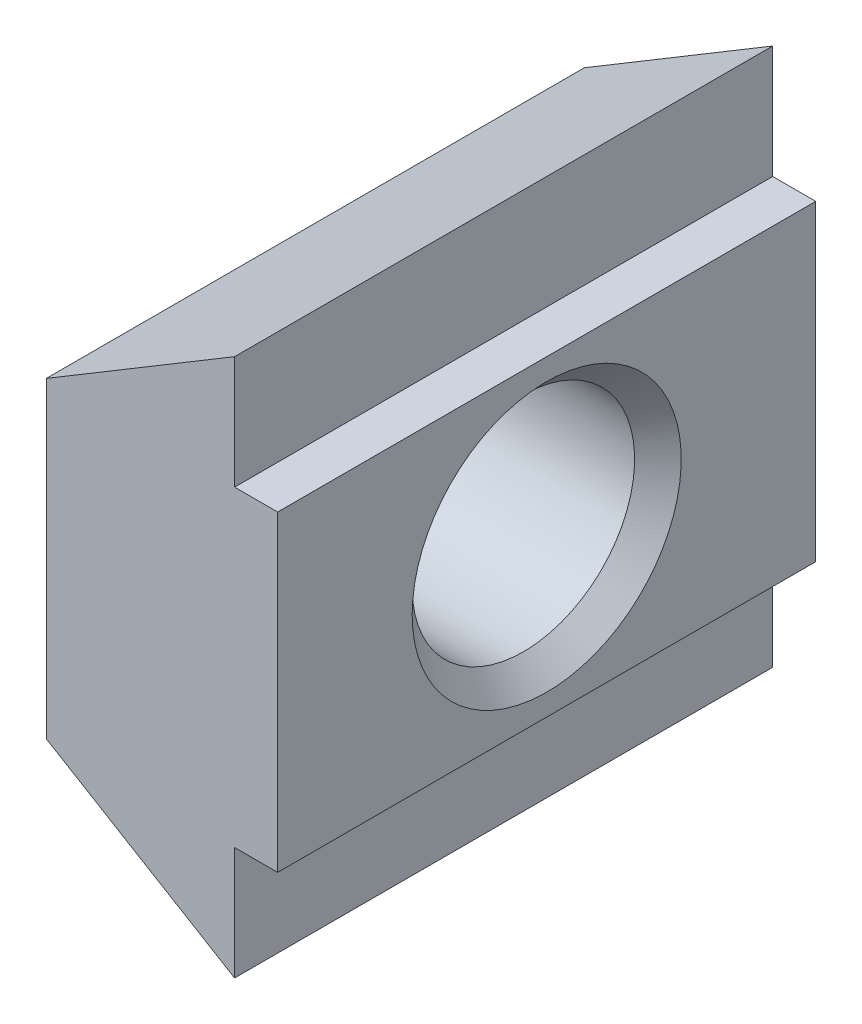
from build123d import *

# Parameters (mm, degrees)
BOSS_EXTRUDE1_DEPTH      = 5
BOSS_EXTRUDE1_DEPTH_BACK = 5


with BuildPart() as part:
    # Sketch1 → Boss-Extrude1 (new body, two sides)
    with BuildSketch(Plane.XY) as boss_extrude1_sk:
        Polygon((-4.3, 2.9), (-4.3, -2.9), (-0.8, -5), (-0.8, -2.9), (0, -2.9), (0, 2.9), (-0.8, 2.9), (-0.8, 5), align=None)
    extrude(amount=BOSS_EXTRUDE1_DEPTH)
    extrude(boss_extrude1_sk.sketch, amount=-BOSS_EXTRUDE1_DEPTH_BACK)

    # Sketch2 → Cut-Revolve1 (revolve, cut)
    with BuildSketch(Plane.XY):
        Polygon((-4.3, 0), (-4.3, 2.5), (-3.867, 2.067), (-0.433, 2.067), (0, 2.5), (0, 0), align=None)
    revolve(axis=Axis((0, 0, 0), (-1, 0, 0)), mode=Mode.SUBTRACT)


solid = part.part
